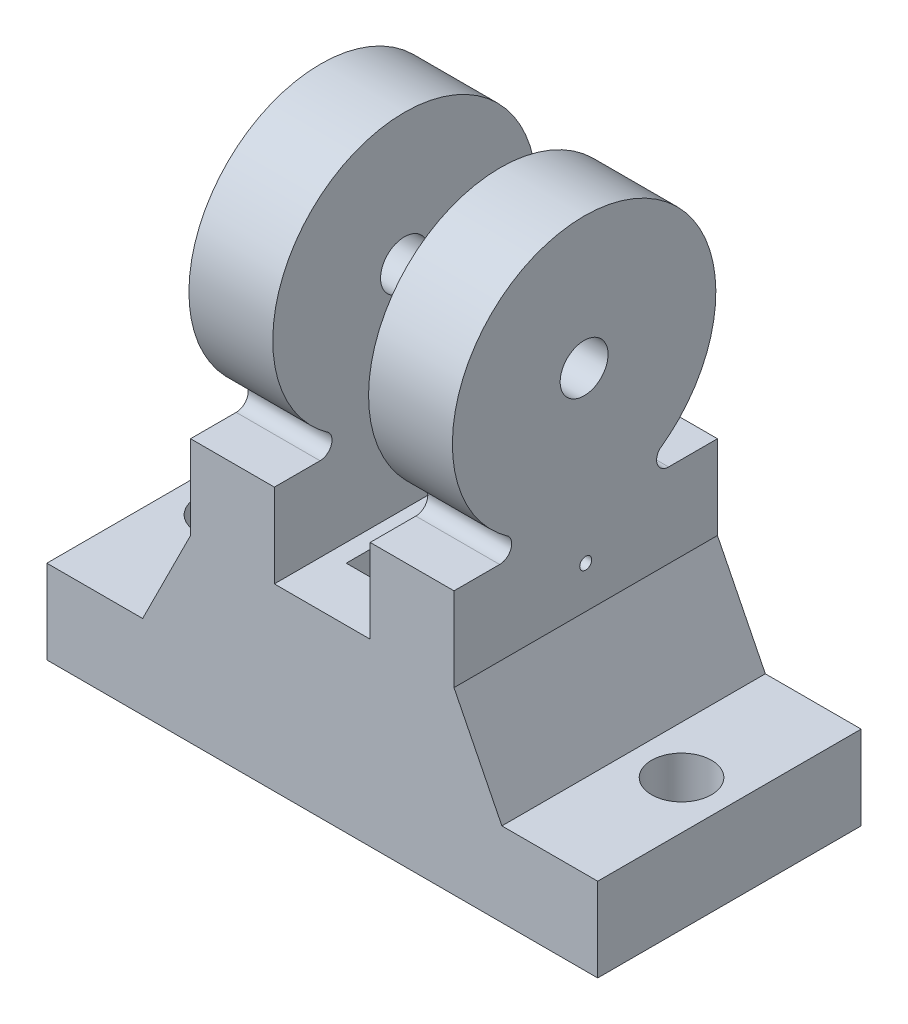
from build123d import *

# Parameters (mm, degrees)
SKETCH1_W                      = 22
SKETCH1_H                      = 22
BODY_BASE_DEPTH                = 20
SKETCH8_W                      = 22
SKETCH8_H                      = 5
CHANNEL_FOR_TENDONS_DEPTH      = 4
BOSS_EXTRUDE2_DEPTH            = 7
LPATTERN1_COUNT                = 2
LPATTERN1_PITCH                = 15
SKETCH11_R                     = 2
CONNECT_TO_GRIPPERS_DEPTH      = 23
BOSS_EXTRUDE3_DEPTH            = 11
SKETCH13_R                     = 2.5
CUT_EXTRUDE3_DEPTH             = 8
SKETCH16_W                     = 5
SKETCH16_H                     = 13
TENDON_PASS_THROUGH_HOLE_DEPTH = 16
SKETCH17_R                     = 0.5
TENDON_PIN_HOLE_DEPTH          = 35


with BuildPart() as part:
    # Sketch1 → Body Base (new body)
    with BuildSketch(Plane(origin=(0, 0, 0), x_dir=(1, 0, 0), z_dir=(0, 1, 0))):
        Rectangle(SKETCH1_W, SKETCH1_H)
    extrude(amount=BODY_BASE_DEPTH)

    # Sketch8 → Channel for Tendons (cut, symmetric)
    with BuildSketch(Plane(origin=(0, 0, 0), x_dir=(0, 0, -1), z_dir=(1, 0, 0))):
        with Locations((0, 17.5)):
            Rectangle(SKETCH8_W, SKETCH8_H)
    extrude(amount=CHANNEL_FOR_TENDONS_DEPTH, both=True, mode=Mode.SUBTRACT)

    # Sketch9 → Boss-Extrude2 (add)
    with BuildSketch(Plane(origin=(11, 0, 0), x_dir=(0, 0, -1), z_dir=(1, 0, 0))):
        with BuildLine():
            Line((-11, 20), (-11, 22))
            Line((-11, 22), (-7.188338132, 22))
            ThreePointArc((-7.188338132, 22), (-6.278997638, 22.58394728), (-6.43167096, 23.653800269))
            ThreePointArc((-6.43167096, 23.653800269), (-0.13450677, 43.67298666), (6.16265742, 23.653800269))
            ThreePointArc((6.16265742, 23.653800269), (6.009984097, 22.58394728), (6.919324592, 22))
            Line((6.919324592, 22), (11, 22))
            Line((11, 22), (11, 20))
            Line((11, 20), (-11, 20))
        make_face()
    boss_extrude2 = extrude(amount=-BOSS_EXTRUDE2_DEPTH)

    # LPattern1: Boss-Extrude2 ×2
    with Locations(*[(-i * LPATTERN1_PITCH, 0, 0) for i in range(1, LPATTERN1_COUNT)]):
        add(boss_extrude2)

    # Sketch11 → Connect to Grippers (cut, through all)
    with BuildSketch(Plane(origin=(11, 0, 0), x_dir=(0, 0, -1), z_dir=(1, 0, 0))):
        with Locations((-0.13450677, 32.67298666)):
            Circle(SKETCH11_R)
    extrude(amount=-CONNECT_TO_GRIPPERS_DEPTH, mode=Mode.SUBTRACT)

    # Sketch12 → Boss-Extrude3 (add, symmetric)
    with BuildSketch(Plane.XY):
        Polygon((-11, 15), (-15, 7), (-23, 7), (-23, 0), (-11, 0), align=None)
        Polygon((11, 15), (15, 7), (23, 7), (23, 0), (11, 0), align=None)
    extrude(amount=BOSS_EXTRUDE3_DEPTH, both=True)

    # Sketch13 → Cut-Extrude3 (cut, through all)
    with BuildSketch(Plane(origin=(0, 7, 0), x_dir=(1, 0, 0), z_dir=(0, 1, 0))):
        with Locations((-19, 0)):
            Circle(SKETCH13_R)
        with Locations((19, 0)):
            Circle(SKETCH13_R)
    extrude(amount=-CUT_EXTRUDE3_DEPTH, mode=Mode.SUBTRACT)

    # Sketch16 → Tendon Pass Through Hole (cut, through all)
    with BuildSketch(Plane(origin=(0, 15, 0), x_dir=(1, 0, 0), z_dir=(0, 1, 0))):
        Rectangle(SKETCH16_W, SKETCH16_H)
    extrude(amount=-TENDON_PASS_THROUGH_HOLE_DEPTH, mode=Mode.SUBTRACT)

    # Sketch17 → Tendon Pin Hole (cut, through all)
    with BuildSketch(Plane.ZY.offset(11)):
        with Locations((0, 18.5)):
            Circle(SKETCH17_R)
    extrude(amount=-TENDON_PIN_HOLE_DEPTH, mode=Mode.SUBTRACT)


solid = part.part
